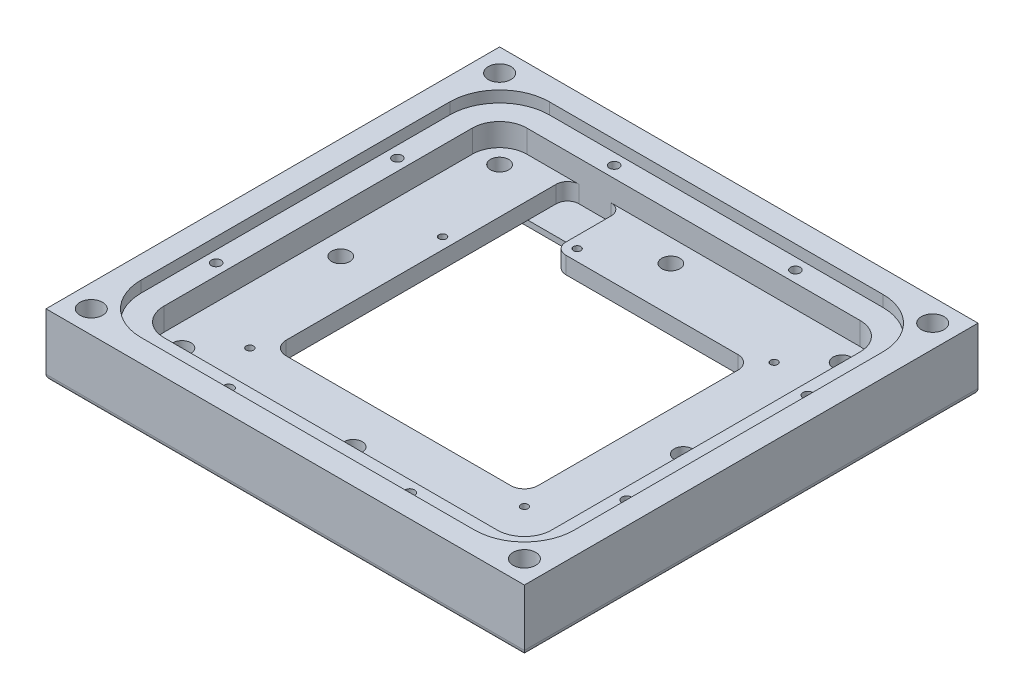
from build123d import *

# Parameters (mm, degrees)
SKETCH2_W                                            = 134.112
SKETCH2_H                                            = 127.1524
SKETCH2_W_2                                          = 83.312
SKETCH2_H_2                                          = 76.3524
SKETCH2_W_3                                          = 21.7424
SKETCH2_H_3                                          = 15.9766
BOSS_EXTRUDE1_DEPTH                                  = 15.875
BOSS_EXTRUDE2_DEPTH                                  = 9.525
CUT_EXTRUDE2_DEPTH                                   = 3.175
M2_5X0_45_TAPPED_HOLE1_D                             = 2.05
M2_5X0_45_TAPPED_HOLE1_DEPTH                         = 6.35
M2_5X0_45_TAPPED_HOLE1_TIP                           = 0.615882135
F_10_CLEARANCE_HOLE1_D                               = 5.1054
CUT_EXTRUDE3_DEPTH                                   = 6.35
CUT_EXTRUDE4_DEPTH                                   = 1.6
SKETCH12_W                                           = 70.612
SKETCH12_H                                           = 63.6524
CUT_EXTRUDE5_DEPTH                                   = 12.1
FILLET1_R                                            = 3.81
SKETCH13_W                                           = 134.112
SKETCH13_H                                           = 127.1524
CUT_EXTRUDE6_DEPTH                                   = 1.5875
FILLET2_R                                            = 1.5875
SKETCH14_W                                           = 15.3924
SKETCH14_H                                           = 22.86
CUT_EXTRUDE7_DEPTH                                   = 4.75
FILLET3_R                                            = 3.175
SKETCH15_W                                           = 134.112
SKETCH15_H                                           = 127.1524
BOSS_EXTRUDE3_DEPTH                                  = 3.175
F_6_32_TAPPED_HOLE1_AT_2_COUNT                       = 2
F_6_32_TAPPED_HOLE1_AT_2_PITCH                       = 108.1024
F_6_32_TAPPED_HOLE1_AT_3_COUNT                       = 2
F_6_32_TAPPED_HOLE1_AT_3_PITCH                       = 85.702359025
F_6_32_TAPPED_HOLE1_AT_4_COUNT                       = 2
F_6_32_TAPPED_HOLE1_AT_4_PITCH                       = 43.049882955
CBORE_FOR_1_4_BINDING_HEAD_MACHINE_SCREW_D           = 6.35
CBORE_FOR_1_4_BINDING_HEAD_MACHINE_SCREW_DEPTH       = 17.4625
CBORE_FOR_1_4_BINDING_HEAD_MACHINE_SCREW_CBORE_D     = 9.525
CBORE_FOR_1_4_BINDING_HEAD_MACHINE_SCREW_CBORE_DEPTH = 6.35


with BuildPart() as part:
    # Sketch2 → Boss-Extrude1 (new body)
    with BuildSketch(Plane(origin=(0, 0, 0), x_dir=(1, 0, 0), z_dir=(0, 1, 0))):
        Rectangle(SKETCH2_W, SKETCH2_H)
        Rectangle(SKETCH2_W_2, SKETCH2_H_2, mode=Mode.SUBTRACT)
        with Locations((-30.7848, 30.1879)):
            Rectangle(SKETCH2_W_3, SKETCH2_H_3)
    extrude(amount=BOSS_EXTRUDE1_DEPTH)

    # Sketch4 → Boss-Extrude2 (add)
    with BuildSketch(Plane(origin=(0, 0, 0), x_dir=(1, 0, 0), z_dir=(0, 1, 0))):
        Polygon((41.656, -38.1762), (41.656, 38.1762), (-19.9136, 38.1762), (-19.9136, 22.1996), (-41.656, 22.1996), (-41.656, -38.1762), align=None)
        Polygon((35.306, 31.8262), (-13.5636, 31.8262), (-13.5636, 15.8496), (-35.306, 15.8496), (-35.306, -31.8262), (35.306, -31.8262), align=None, mode=Mode.SUBTRACT)
    extrude(amount=BOSS_EXTRUDE2_DEPTH)

    # Sketch5 → Cut-Extrude2 (cut)
    with BuildSketch(Plane.XZ):
        with BuildLine():
            Line((46.736, -50.8762), (-46.736, -50.8762))
            ThreePointArc((-46.736, -50.8762), (-52.124153673, -48.644353673), (-54.356, -43.2562))
            Line((-54.356, -43.2562), (-54.356, 43.2562))
            ThreePointArc((-54.356, 43.2562), (-52.124153673, 48.644353673), (-46.736, 50.8762))
            Line((-46.736, 50.8762), (46.736, 50.8762))
            ThreePointArc((46.736, 50.8762), (52.124153673, 48.644353673), (54.356, 43.2562))
            Line((54.356, 43.2562), (54.356, -43.2562))
            ThreePointArc((54.356, -43.2562), (52.124153673, -48.644353673), (46.736, -50.8762))
        make_face()
    extrude(amount=-CUT_EXTRUDE2_DEPTH, mode=Mode.SUBTRACT)

    # M2.5x0.45 Tapped Hole1
    with Locations(Plane(origin=(0, 3.175, 0), x_dir=(-1, 0, 0), z_dir=(0, -1, 0))):
        with Locations((38.481, -35.0012), (-38.481, -35.0012), (38.481, 19.0246), (16.7386, 35.0012), (-38.481, 35.0012)):
            Hole(M2_5X0_45_TAPPED_HOLE1_D / 2, depth=M2_5X0_45_TAPPED_HOLE1_DEPTH)
            with Locations((0, 0, -(M2_5X0_45_TAPPED_HOLE1_DEPTH + M2_5X0_45_TAPPED_HOLE1_TIP / 2))):  # 118° drill point
                Cone(0, M2_5X0_45_TAPPED_HOLE1_D / 2, M2_5X0_45_TAPPED_HOLE1_TIP, mode=Mode.SUBTRACT)

    # 10 Clearance Hole1 (through all)
    with Locations(Plane(origin=(0, 3.175, 0), x_dir=(-1, 0, 0), z_dir=(0, -1, 0))):
        with Locations((48.006, -44.5262), (0, -44.5262), (-48.006, -44.5262), (-48.006, 0), (-48.006, 44.5262), (0, 44.5262), (48.006, 44.5262), (48.006, 0)):
            Hole(F_10_CLEARANCE_HOLE1_D / 2)

    # Sketch10 → Cut-Extrude3 (cut)
    with BuildSketch(Plane(origin=(0, 15.875, 0), x_dir=(1, 0, 0), z_dir=(0, 1, 0))):
        with BuildLine():
            Line((54.356, -43.2562), (54.356, 43.2562))
            ThreePointArc((54.356, 43.2562), (52.124153673, 48.644353673), (46.736, 50.8762))
            Line((46.736, 50.8762), (-46.736, 50.8762))
            ThreePointArc((-46.736, 50.8762), (-52.124153673, 48.644353673), (-54.356, 43.2562))
            Line((-54.356, 43.2562), (-54.356, -43.2562))
            ThreePointArc((-54.356, -43.2562), (-52.124153673, -48.644353673), (-46.736, -50.8762))
            Line((-46.736, -50.8762), (46.736, -50.8762))
            ThreePointArc((46.736, -50.8762), (52.124153673, -48.644353673), (54.356, -43.2562))
        make_face()
    extrude(amount=-CUT_EXTRUDE3_DEPTH, mode=Mode.SUBTRACT)

    # Sketch11 → Cut-Extrude4 (cut)
    with BuildSketch(Plane.XZ.offset(-3.175)):
        with BuildLine():
            Line((40.0685, 39.7637), (-40.0685, 39.7637))
            ThreePointArc((-40.0685, 39.7637), (-42.31356403, 38.83376403), (-43.2435, 36.5887))
            Line((-43.2435, 36.5887), (-43.2435, -36.5887))
            ThreePointArc((-43.2435, -36.5887), (-42.31356403, -38.83376403), (-40.0685, -39.7637))
            Line((-40.0685, -39.7637), (40.0685, -39.7637))
            ThreePointArc((40.0685, -39.7637), (42.31356403, -38.83376403), (43.2435, -36.5887))
            Line((43.2435, -36.5887), (43.2435, 36.5887))
            ThreePointArc((43.2435, 36.5887), (42.31356403, 38.83376403), (40.0685, 39.7637))
        make_face()
    extrude(amount=-CUT_EXTRUDE4_DEPTH, mode=Mode.SUBTRACT)

    # Sketch12 → Cut-Extrude5 (cut, through all)
    with BuildSketch(Plane.XZ.offset(-4.775)):
        Rectangle(SKETCH12_W, SKETCH12_H)
    extrude(amount=-CUT_EXTRUDE5_DEPTH, mode=Mode.SUBTRACT)

    # Fillet1
    fillet1_edges = [part.edges().sort_by_distance(p)[0] for p in [
        (-35.306, 7.15, -31.8262),
        (35.306, 7.15, -31.8262),
        (-35.306, 7.15, 31.8262),
        (35.306, 7.15, 31.8262),
    ]]
    fillet(fillet1_edges, radius=FILLET1_R)

    # Sketch13 → Cut-Extrude6 (cut)
    with BuildSketch(Plane.XZ):
        Rectangle(SKETCH13_W, SKETCH13_H)
        with BuildLine():
            Line((54.356, -43.2562), (54.356, 43.2562))
            ThreePointArc((54.356, 43.2562), (52.124153673, 48.644353673), (46.736, 50.8762))
            Line((46.736, 50.8762), (-46.736, 50.8762))
            ThreePointArc((-46.736, 50.8762), (-52.124153673, 48.644353673), (-54.356, 43.2562))
            Line((-54.356, 43.2562), (-54.356, -43.2562))
            ThreePointArc((-54.356, -43.2562), (-52.124153673, -48.644353673), (-46.736, -50.8762))
            Line((-46.736, -50.8762), (46.736, -50.8762))
            ThreePointArc((46.736, -50.8762), (52.124153673, -48.644353673), (54.356, -43.2562))
        make_face(mode=Mode.SUBTRACT)
    extrude(amount=-CUT_EXTRUDE6_DEPTH, mode=Mode.SUBTRACT)

    # Fillet2
    fillet2_edges = [part.edges().sort_by_distance(p)[0] for p in [
        (67.056, 1.5875, 0),
        (0, 1.5875, -63.5762),
        (-67.056, 1.5875, 0),
        (0, 1.5875, 63.5762),
    ]]
    fillet(fillet2_edges, radius=FILLET2_R)

    # Sketch14 → Cut-Extrude7 (cut)
    with BuildSketch(Plane(origin=(0, 9.525, 0), x_dir=(1, 0, 0), z_dir=(0, 1, 0))):
        with Locations((-27.6098, 39.4462)):
            Rectangle(SKETCH14_W, SKETCH14_H)
    extrude(amount=-CUT_EXTRUDE7_DEPTH, mode=Mode.SUBTRACT)

    # Fillet3
    fillet3_edges = [part.edges().sort_by_distance(p)[0] for p in [
        (-19.9136, 7.15, -31.8262),
        (-19.9136, 7.15, -50.8762),
        (-35.306, 7.15, -50.8762),
    ]]
    fillet(fillet3_edges, radius=FILLET3_R)

    # Sketch15 → Boss-Extrude3 (add)
    with BuildSketch(Plane(origin=(0, 15.875, 0), x_dir=(1, 0, 0), z_dir=(0, 1, 0))):
        Rectangle(SKETCH15_W, SKETCH15_H)
        with BuildLine():
            ThreePointArc((46.736, -57.2262), (56.614281733, -53.134481733), (60.706, -43.2562))
            Line((60.706, -43.2562), (60.706, 43.2562))
            ThreePointArc((60.706, 43.2562), (56.614281733, 53.134481733), (46.736, 57.2262))
            Line((46.736, 57.2262), (-46.736, 57.2262))
            ThreePointArc((-46.736, 57.2262), (-56.614281733, 53.134481733), (-60.706, 43.2562))
            Line((-60.706, 43.2562), (-60.706, -43.2562))
            ThreePointArc((-60.706, -43.2562), (-56.614281733, -53.134481733), (-46.736, -57.2262))
            Line((-46.736, -57.2262), (46.736, -57.2262))
        make_face(mode=Mode.SUBTRACT)
    extrude(amount=BOSS_EXTRUDE3_DEPTH)

    # Sketch18 → 6-32 Tapped Hole1 (revolve, cut)
    with BuildSketch(Plane(origin=(-25.4, 15.875, 54.0512), x_dir=(0, 0, 1), z_dir=(1, 0, 0))):
        Polygon((0, 0), (0, 10.33769403), (1.35255, 9.525), (1.35255, 0), align=None)
    f_6_32_tapped_hole1 = revolve(axis=Axis((-25.4, 22.225, 54.0512), (0, -1, 0)), mode=Mode.SUBTRACT)

    # 6-32 Tapped Hole1 at 2: 6-32 Tapped Hole1 ×2
    with Locations(*[(0, 0, -i * F_6_32_TAPPED_HOLE1_AT_2_PITCH) for i in range(1, F_6_32_TAPPED_HOLE1_AT_2_COUNT)]):
        add(f_6_32_tapped_hole1, mode=Mode.SUBTRACT)

    # 6-32 Tapped Hole1 at 3: 6-32 Tapped Hole1 ×2
    with Locations(*[Vector(-0.374913834, 0, -0.927059662) * (i * F_6_32_TAPPED_HOLE1_AT_3_PITCH) for i in range(1, F_6_32_TAPPED_HOLE1_AT_3_COUNT)]):
        add(f_6_32_tapped_hole1, mode=Mode.SUBTRACT)

    # 6-32 Tapped Hole1 at 4: 6-32 Tapped Hole1 ×2
    with Locations(*[Vector(-0.746366721, 0, -0.665534911) * (i * F_6_32_TAPPED_HOLE1_AT_4_PITCH) for i in range(1, F_6_32_TAPPED_HOLE1_AT_4_COUNT)]):
        add(f_6_32_tapped_hole1, mode=Mode.SUBTRACT)

    # Mirror1: 6-32 Tapped Hole1 across plane
    add(f_6_32_tapped_hole1.mirror(Plane(origin=(0, 0, 0), x_dir=(0, 0, 1), z_dir=(1, 0, 0))), mode=Mode.SUBTRACT)

    # Mirror1 copy 1 sketch → Mirror1 copy 1 (revolve, cut)
    with BuildSketch(Plane(origin=(25.4, 15.875, -54.0512), x_dir=(0, 0, 1), z_dir=(-1, 0, 0))):
        Polygon((0, 0), (0, -10.33769403), (1.35255, -9.525), (1.35255, 0), align=None)
    revolve(axis=Axis((25.4, 22.225, -54.0512), (0, 1, 0)), mode=Mode.SUBTRACT)

    # Mirror1 copy 2 sketch → Mirror1 copy 2 (revolve, cut)
    with BuildSketch(Plane(origin=(57.531, 15.875, -25.4), x_dir=(0, 0, 1), z_dir=(-1, 0, 0))):
        Polygon((0, 0), (0, -10.33769403), (1.35255, -9.525), (1.35255, 0), align=None)
    revolve(axis=Axis((57.531, 22.225, -25.4), (0, 1, 0)), mode=Mode.SUBTRACT)

    # Mirror1 copy 3 sketch → Mirror1 copy 3 (revolve, cut)
    with BuildSketch(Plane(origin=(57.531, 15.875, 25.4), x_dir=(0, 0, 1), z_dir=(-1, 0, 0))):
        Polygon((0, 0), (0, -10.33769403), (1.35255, -9.525), (1.35255, 0), align=None)
    revolve(axis=Axis((57.531, 22.225, 25.4), (0, 1, 0)), mode=Mode.SUBTRACT)

    # CBORE for 1_4 Binding Head Machine Screw
    with Locations(Plane(origin=(0, 1.5875, 0), x_dir=(-1, 0, 0), z_dir=(0, -1, 0))):
        with Locations((60.706, -57.2262), (-60.706, -57.2262), (-60.706, 57.2262), (60.706, 57.2262)):
            CounterBoreHole(CBORE_FOR_1_4_BINDING_HEAD_MACHINE_SCREW_D / 2, CBORE_FOR_1_4_BINDING_HEAD_MACHINE_SCREW_CBORE_D / 2, CBORE_FOR_1_4_BINDING_HEAD_MACHINE_SCREW_CBORE_DEPTH, depth=CBORE_FOR_1_4_BINDING_HEAD_MACHINE_SCREW_DEPTH)


solid = part.part
